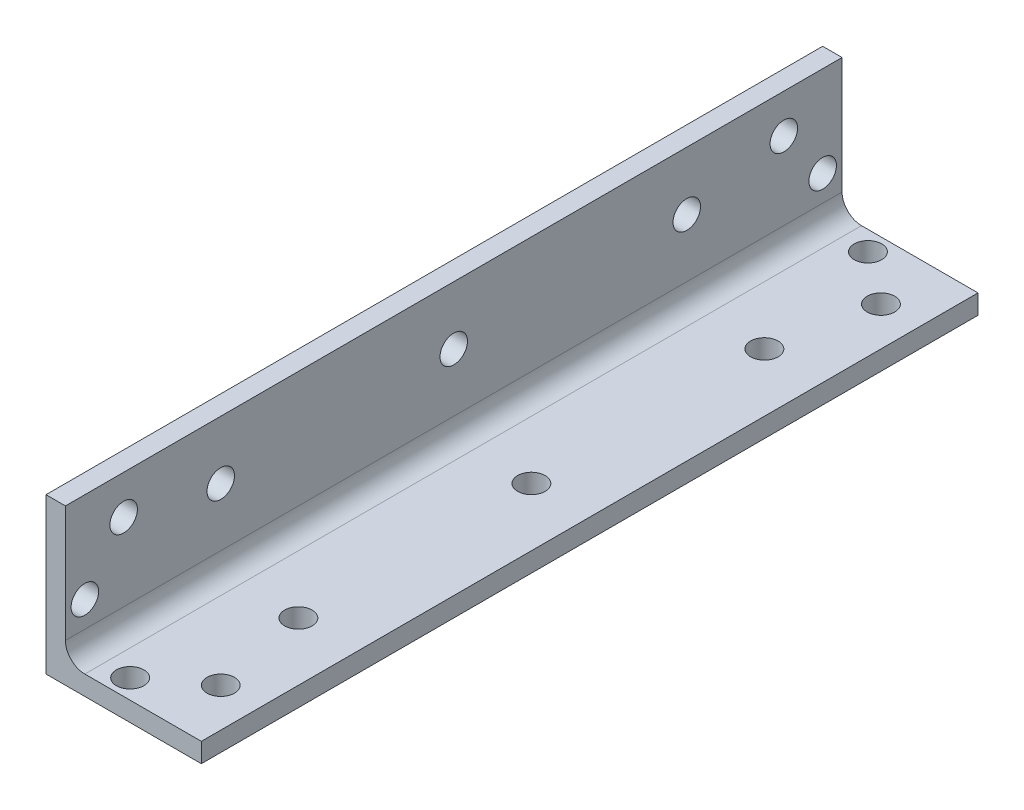
from build123d import *

# Parameters (mm, degrees)
BOSS_EXTRUDE1_DEPTH = 63.5
FILLET1_R           = 3.175
SKETCH2_R           = 2.25
CUT_EXTRUDE1_DEPTH  = 26.4


with BuildPart() as part:
    # Sketch1 → Boss-Extrude1 (new body, symmetric)
    with BuildSketch(Plane.XY):
        Polygon((0, 25.4), (0, 0), (25.4, 0), (25.4, 3.175), (3.175, 3.175), (3.175, 25.4), align=None)
    extrude(amount=BOSS_EXTRUDE1_DEPTH, both=True)

    # Fillet1
    fillet1_edges = [part.edges().sort_by_distance(p)[0] for p in [
        (3.175, 3.175, 0),
    ]]
    fillet(fillet1_edges, radius=FILLET1_R)

    # Sketch2 → Cut-Extrude1 (cut, through all)
    with BuildSketch(Plane.XZ):
        with Locations((19.05, -53.975)):
            Circle(SKETCH2_R)
        with Locations((10.583333333, -60.325)):
            Circle(SKETCH2_R)
        with Locations((10.583333333, 60.325)):
            Circle(SKETCH2_R)
        with Locations((19.05, 53.975)):
            Circle(SKETCH2_R)
        with Locations((15.87, 38.1)):
            Circle(SKETCH2_R)
        with Locations((15.87, 0)):
            Circle(SKETCH2_R)
        with Locations((15.87, -38.1)):
            Circle(SKETCH2_R)
    cut_extrude1 = extrude(amount=-CUT_EXTRUDE1_DEPTH, mode=Mode.SUBTRACT)

    # Mirror1: Cut-Extrude1 across plane
    add(cut_extrude1.mirror(Plane(origin=(0, 0, 0), x_dir=(0, 0, 1), z_dir=(0.707106781, -0.707106781, 0))), mode=Mode.SUBTRACT)


solid = part.part
